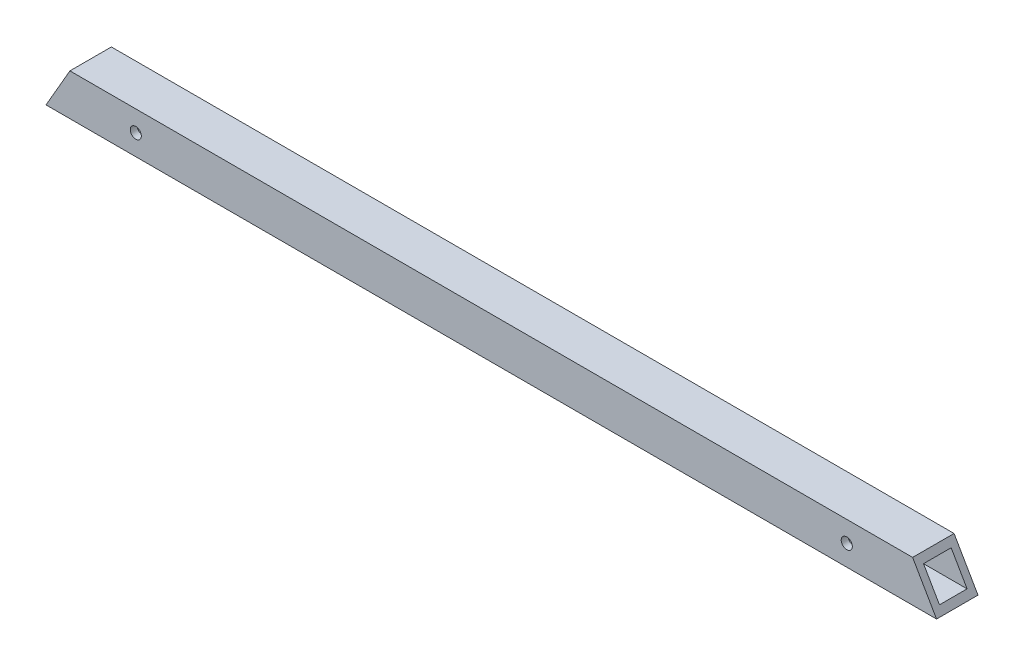
from build123d import *

# Parameters (mm, degrees)
SKETCH1_W              = 19.05
SKETCH1_H              = 19.05
SKETCH1_W_2            = 12.7
SKETCH1_H_2            = 12.7
BOSS_EXTRUDE1_DEPTH    = 431.8
CUT_EXTRUDE1_DEPTH     = 20.05
F_10_CLEARANCE_HOLE1_D = 5.1054


with BuildPart() as part:
    # Sketch1 → Boss-Extrude1 (new body)
    with BuildSketch(Plane(origin=(0, 0, 0), x_dir=(0, 0, -1), z_dir=(1, 0, 0))):
        with Locations((9.525, 9.525)):
            Rectangle(SKETCH1_W, SKETCH1_H)
        with Locations((9.525, 9.525)):
            Rectangle(SKETCH1_W_2, SKETCH1_H_2, mode=Mode.SUBTRACT)
    extrude(amount=BOSS_EXTRUDE1_DEPTH)

    # Sketch2 → Cut-Extrude1 (cut, through all)
    with BuildSketch(Plane.XY):
        Polygon((398.348522628, 19.05), (409.347045256, 0), (431.8, 0), (431.8, 19.05), align=None)
        Polygon((0, 19.05), (0, 0), (10.998522628, 19.05), align=None)
    extrude(amount=-CUT_EXTRUDE1_DEPTH, mode=Mode.SUBTRACT)

    # #10 Clearance Hole1 (through all)
    with Locations(Plane(origin=(368.072045256, 9.525, 0), x_dir=(1, 0, 0), z_dir=(0, 0, 1))):
        with Locations((0, 0), (-326.797045256, 0)):
            Hole(F_10_CLEARANCE_HOLE1_D / 2)


solid = part.part
